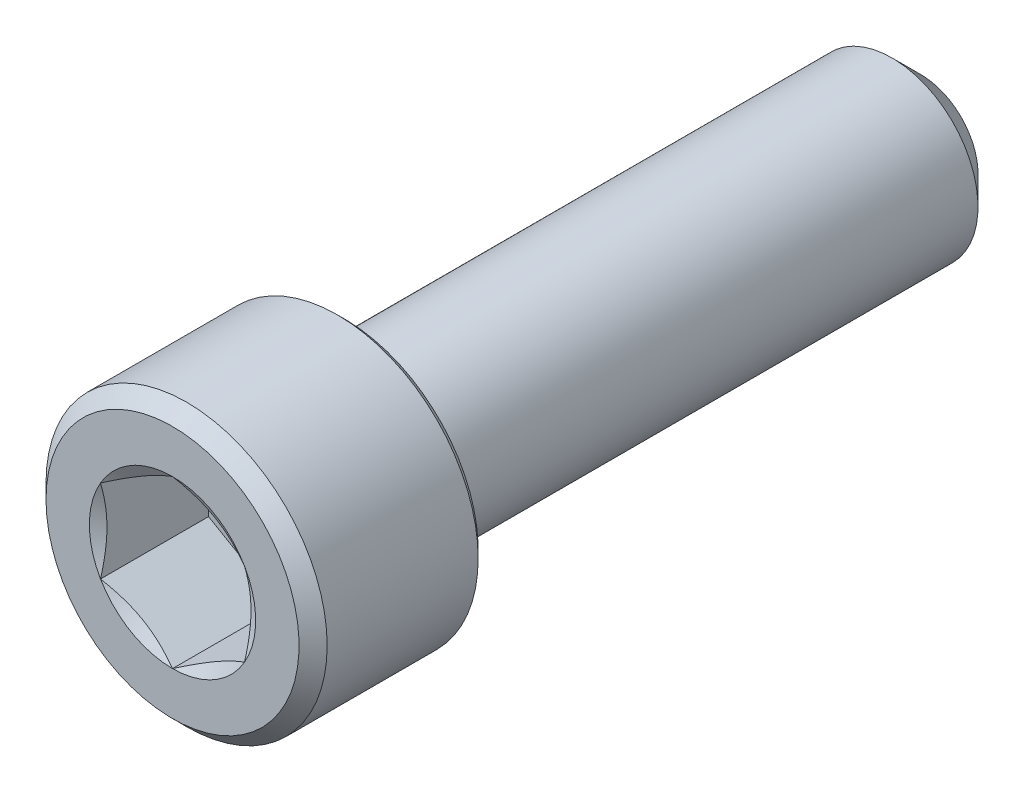
from build123d import *

# Parameters (mm, degrees)
CUT_EXTRUDE1_DEPTH = 1.7859375
CHAMFER1_SIZE      = 0.23241
CHAMFER2_SIZE      = 0.116205


with BuildPart() as part:
    # Sketch2 → Revolve1 (revolve)
    with BuildSketch(Plane(origin=(0, 0, 0), x_dir=(0, 0, -1), z_dir=(1, 0, 0))):
        Polygon((6.1849, 0.94615), (5.70865, 1.4224), (-3.3401, 1.4224), (-3.3401, 2.3241), (-6.1849, 2.3241), (-6.1849, 0), (6.1849, 0), align=None)
    revolve(axis=Axis((0, 0, -6.1849), (0, 0, 1)))

    # Sketch4 → Cut-Extrude1 (cut)
    with BuildSketch(Plane.XY.offset(6.1849)):
        Polygon((0, 1.374815329), (-1.190625, 0.687407664), (-1.190625, -0.687407664), (0, -1.374815329), (1.190625, -0.687407664), (1.190625, 0.687407664), align=None)
    extrude(amount=-CUT_EXTRUDE1_DEPTH, mode=Mode.SUBTRACT)

    # Cut-Extrude2 cone 1 section (through the dimple's axis) → Cut-Extrude2 (revolve, cut)
    with BuildSketch(Plane(origin=(0, 0, 6.1849), x_dir=(0, -1, 0), z_dir=(1, 0, 0))):
        Polygon((0, 0), (1.374815329, 0), (0, 0.79375), align=None)
    revolve(axis=Axis((0, 0, 6.1849), (0, 0, -1)), mode=Mode.SUBTRACT)

    # Chamfer1
    chamfer1_edges = [part.edges().sort_by_distance(p)[0] for p in [
        (0, -2.3241, 6.1849),
    ]]
    chamfer(chamfer1_edges, length=CHAMFER1_SIZE)

    # Chamfer2
    chamfer2_edges = [part.edges().sort_by_distance(p)[0] for p in [
        (0, -2.3241, 3.3401),
    ]]
    chamfer(chamfer2_edges, length=CHAMFER2_SIZE)


solid = part.part
